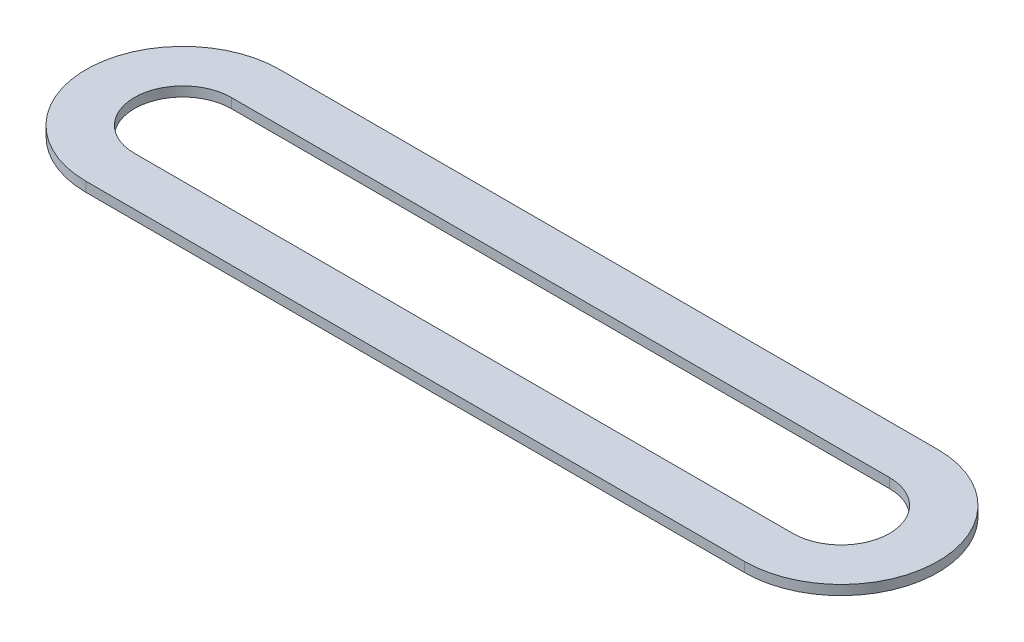
from build123d import *

# Parameters (mm, degrees)
BOSS_EXTRUDE1_DEPTH = 0.5


with BuildPart() as part:
    # Sketch1 → Boss-Extrude1 (new body)
    with BuildSketch(Plane(origin=(0, 0, 0), x_dir=(1, 0, 0), z_dir=(0, 1, 0))):
        with BuildLine():
            ThreePointArc((0, -5), (5, 0), (0, 5))
            Line((0, 5), (-34, 5))
            ThreePointArc((-34, 5), (-39, 0), (-34, -5))
            Line((-34, -5), (0, -5))
        make_face()
        with BuildLine():
            ThreePointArc((-34, -2.5), (-36.5, 0), (-34, 2.5))
            Line((-34, 2.5), (0, 2.5))
            ThreePointArc((0, 2.5), (2.5, 0), (0, -2.5))
            Line((0, -2.5), (-34, -2.5))
        make_face(mode=Mode.SUBTRACT)
    extrude(amount=BOSS_EXTRUDE1_DEPTH)


solid = part.part
